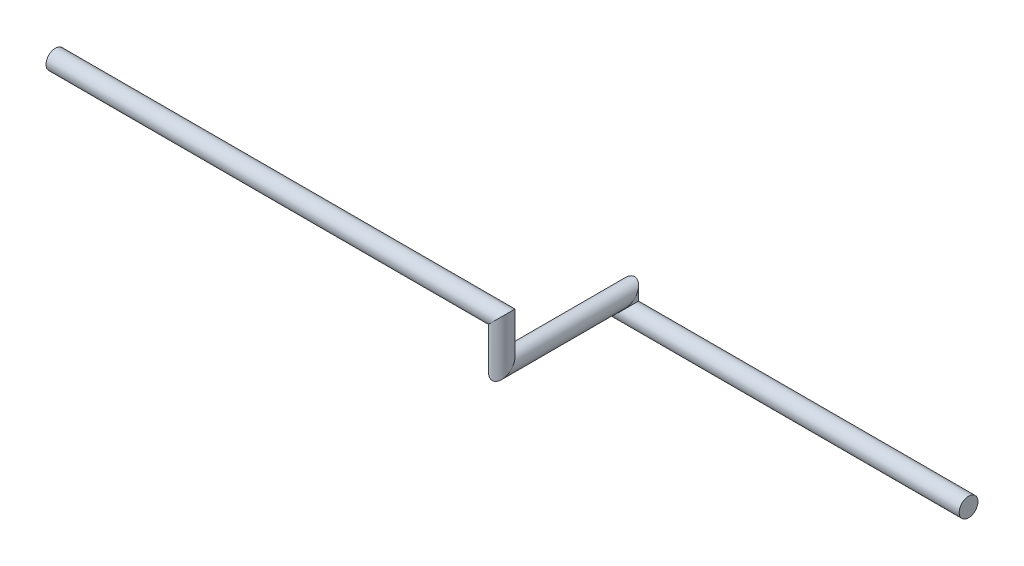
from build123d import *

# Parameters (mm, degrees)
CROQUIS1_R = 13.7


with BuildPart() as part:
    # Barrer1: sweep along a curve in space
    with BuildLine() as barrer1_path:
        Line((0, 0, 0), (-500, 0, 0))
        Line((-500, 0, 0), (-500, 20, 0))
        Line((-500, 20, 0), (-500, 20, 180))
        Line((-500, 20, 180), (-500, 80, 180))
        Line((-500, 80, 180), (-1150, 80, 180))
    # Croquis1 → Barrer1 (sweep)
    with BuildSketch(Plane(origin=(0, 0, 0), x_dir=(0, 0, -1), z_dir=(1, 0, 0))):
        Circle(CROQUIS1_R)
    sweep(path=barrer1_path.line, transition=Transition.RIGHT)


solid = part.part
